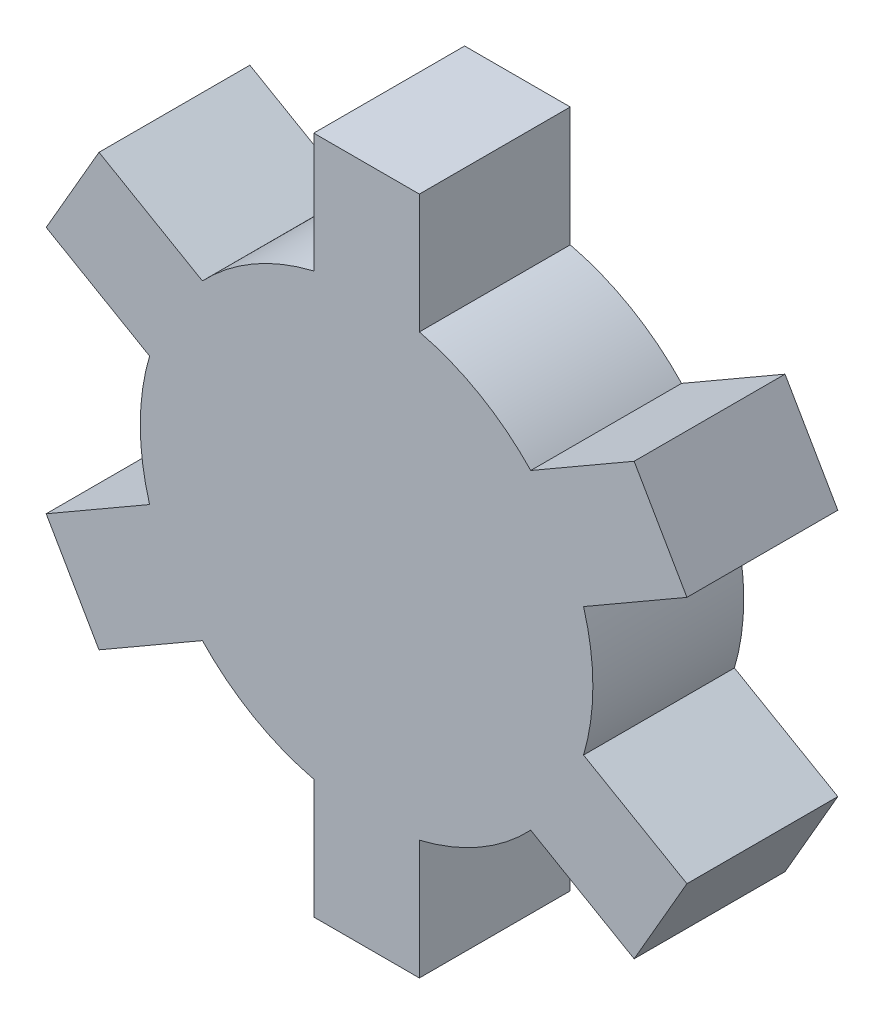
from build123d import *

# Parameters (mm, degrees)
SKETCH1_R           = 15
BOSS_EXTRUDE1_DEPTH = 10
SKETCH2_W           = 7
SKETCH2_H           = 15
BOSS_EXTRUDE2_DEPTH = 10
CIRPATTERN1_COUNT   = 6


with BuildPart() as part:
    # Sketch1 → Boss-Extrude1 (new body)
    with BuildSketch(Plane.XY):
        Circle(SKETCH1_R)
    extrude(amount=BOSS_EXTRUDE1_DEPTH)

    # Sketch2 → Boss-Extrude2 (add)
    with BuildSketch(Plane.XY.offset(10)):
        with Locations((0, 15)):
            Rectangle(SKETCH2_W, SKETCH2_H)
    boss_extrude2 = extrude(amount=-BOSS_EXTRUDE2_DEPTH)

    # CirPattern1: Boss-Extrude2 ×6 about axis
    cirpattern1_axis = Axis((0, 0, 0), (0, 0, 1))
    for i in range(1, CIRPATTERN1_COUNT):
        add(boss_extrude2.rotate(cirpattern1_axis, i * 360 / CIRPATTERN1_COUNT))


solid = part.part
